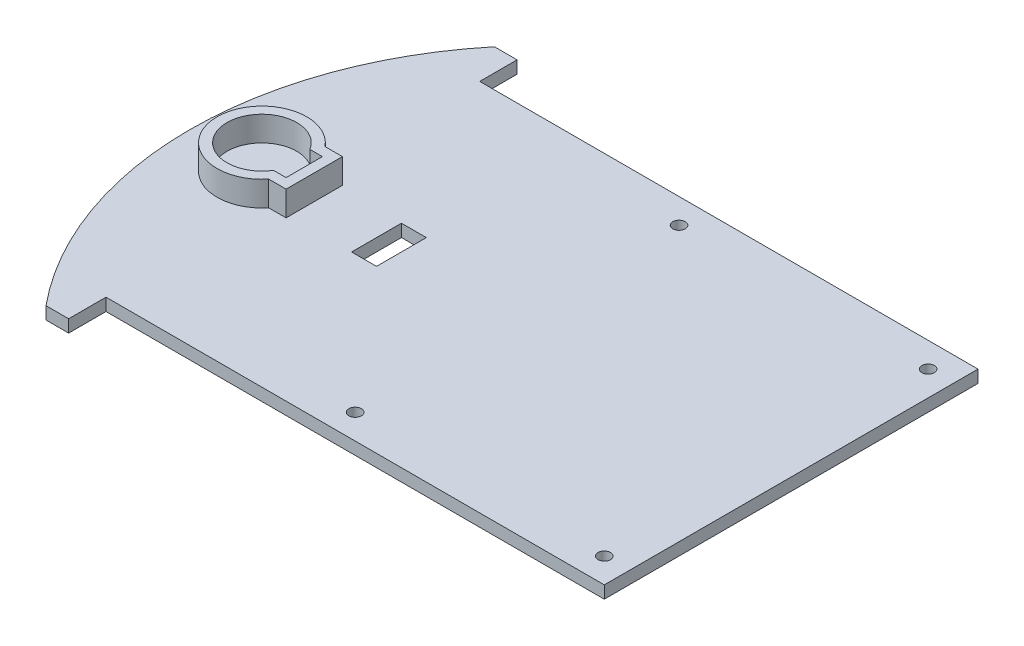
from build123d import *

# Parameters (mm, degrees)
CROQUIS1_R              = 2.5
SALIENTE_EXTRUIR1_DEPTH = 5
SALIENTE_EXTRUIR3_DEPTH = 10
CROQUIS4_W              = 10
CROQUIS4_H              = 20
CORTAR_EXTRUIR1_DEPTH   = 6


with BuildPart() as part:
    # Croquis1 → Saliente-Extruir1 (new body)
    with BuildSketch(Plane(origin=(0, 0, 0), x_dir=(1, 0, 0), z_dir=(0, 1, 0))):
        with BuildLine():
            Line((-71.215351812, -100.39445629), (-71.215351812, -85.39445629))
            Line((-71.215351812, -85.39445629), (128.784648188, -85.39445629))
            Line((128.784648188, -85.39445629), (128.784648188, 64.60554371))
            Line((128.784648188, 64.60554371), (-71.215351812, 64.60554371))
            Line((-71.215351812, 64.60554371), (-71.215351812, 79.60554371))
            Line((-71.215351812, 79.60554371), (-80.302472959, 79.60554371))
            ThreePointArc((-80.302472959, 79.60554371), (-112.63670805, -10.39445629), (-80.302472959, -100.39445629))
            Line((-80.302472959, -100.39445629), (-71.215351812, -100.39445629))
        make_face()
        with Locations((118.784648188, 54.60554371)):
            Circle(CROQUIS1_R, mode=Mode.SUBTRACT)
        with Locations((18.784648188, -75.39445629)):
            Circle(CROQUIS1_R, mode=Mode.SUBTRACT)
        with Locations((118.784648188, -75.39445629)):
            Circle(CROQUIS1_R, mode=Mode.SUBTRACT)
        with Locations((18.784648188, 54.60554371)):
            Circle(CROQUIS1_R, mode=Mode.SUBTRACT)
    extrude(amount=SALIENTE_EXTRUIR1_DEPTH)

    # Croquis3 → Saliente-Extruir3 (add)
    with BuildSketch(Plane(origin=(0, 5, 0), x_dir=(1, 0, 0), z_dir=(0, 1, 0))):
        with BuildLine():
            Line((-101.63670805, -10.39445629), (-97.63670805, -10.39445629))
            ThreePointArc((-97.63670805, -10.39445629), (-89.972723776, 2.089729896), (-75.371721661, 0.90554371))
            Line((-75.371721661, 0.90554371), (-69.625640995, 0.90554371))
            ThreePointArc((-69.625640995, 0.90554371), (-89.62840201, 6.579040801), (-101.63670805, -10.39445629))
        make_face()
        with BuildLine():
            ThreePointArc((-75.371721661, -21.69445629), (-89.972723776, -22.878642476), (-97.63670805, -10.39445629))
            Line((-97.63670805, -10.39445629), (-101.63670805, -10.39445629))
            ThreePointArc((-101.63670805, -10.39445629), (-89.62840201, -27.367953381), (-69.625640995, -21.69445629))
            Line((-69.625640995, -21.69445629), (-75.371721661, -21.69445629))
        make_face()
        with BuildLine():
            ThreePointArc((-71.69057897, -17.69445629), (-73.335140348, -19.874841455), (-75.371721661, -21.69445629))
            Line((-75.371721661, -21.69445629), (-69.625640995, -21.69445629))
            ThreePointArc((-69.625640995, -21.69445629), (-68.273800946, -19.7742796), (-67.183440897, -17.69445629))
            Line((-67.183440897, -17.69445629), (-71.69057897, -17.69445629))
        make_face()
        with BuildLine():
            Line((-62.63670805, 0.90554371), (-69.625640995, 0.90554371))
            ThreePointArc((-69.625640995, 0.90554371), (-68.273800946, -1.01463298), (-67.183440897, -3.09445629))
            Line((-67.183440897, -3.09445629), (-66.63670805, -3.09445629))
            Line((-66.63670805, -3.09445629), (-66.63670805, -4.478376507))
            ThreePointArc((-66.63670805, -4.478376507), (-65.8884687, -7.39445629), (-65.63670805, -10.39445629))
            ThreePointArc((-65.63670805, -10.39445629), (-65.8884687, -13.39445629), (-66.63670805, -16.310536073))
            Line((-66.63670805, -16.310536073), (-66.63670805, -17.69445629))
            Line((-66.63670805, -17.69445629), (-67.183440897, -17.69445629))
            ThreePointArc((-67.183440897, -17.69445629), (-68.273800946, -19.7742796), (-69.625640995, -21.69445629))
            Line((-69.625640995, -21.69445629), (-62.63670805, -21.69445629))
            Line((-62.63670805, -21.69445629), (-62.63670805, 0.90554371))
        make_face()
        with BuildLine():
            Line((-66.63670805, -4.478376507), (-66.63670805, -10.39445629))
            Line((-66.63670805, -10.39445629), (-66.63670805, -16.310536073))
            ThreePointArc((-66.63670805, -16.310536073), (-65.8884687, -13.39445629), (-65.63670805, -10.39445629))
            ThreePointArc((-65.63670805, -10.39445629), (-65.8884687, -7.39445629), (-66.63670805, -4.478376507))
        make_face()
        with BuildLine():
            Line((-69.625640995, 0.90554371), (-75.371721661, 0.90554371))
            ThreePointArc((-75.371721661, 0.90554371), (-73.335140348, -0.914071125), (-71.69057897, -3.09445629))
            Line((-71.69057897, -3.09445629), (-67.183440897, -3.09445629))
            ThreePointArc((-67.183440897, -3.09445629), (-68.273800946, -1.01463298), (-69.625640995, 0.90554371))
        make_face()
    extrude(amount=SALIENTE_EXTRUIR3_DEPTH)

    # Croquis4 → Cortar-Extruir1 (cut)
    with BuildSketch(Plane(origin=(0, 5, 0), x_dir=(1, 0, 0), z_dir=(0, 1, 0))):
        with Locations((-32.63670805, -10.39445629)):
            Rectangle(CROQUIS4_W, CROQUIS4_H)
    extrude(amount=-CORTAR_EXTRUIR1_DEPTH, mode=Mode.SUBTRACT)


solid = part.part
